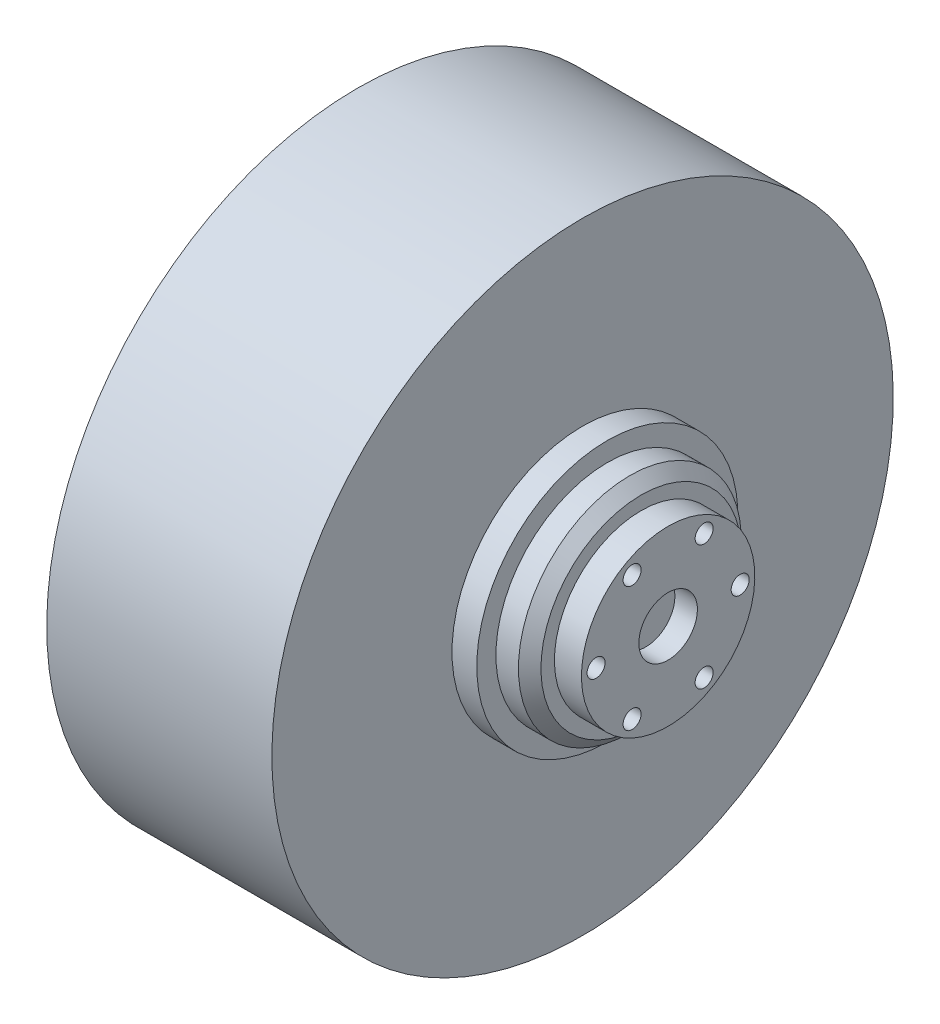
from build123d import *

# Parameters (mm, degrees)
SZKIC4_R                   = 4
WYTNIJ_WYCI_GNI_CIE1_DEPTH = 10
SZKIC5_R                   = 13
WYTNIJ_WYCI_GNI_CIE2_DEPTH = 10


with BuildPart() as part:
    # Szkic1 → Obrót1 (revolve)
    with BuildSketch(Plane.XY):
        Polygon((-90, -36.5), (-70, -36.5), (-70, -47), (-48, -47), (-48, -138), (52, -138), (52, -58), (63, -58), (63, -49.5), (73, -49.5), (78, -44.5), (78, -38.5), (90, -38.5), (90, 0), (-90, 0), align=None)
    revolve(axis=Axis((90, 0, 0), (-1, 0, 0)))

    # Szkic4 → Wytnij-wyciągnięcie1 (cut)
    with BuildSketch(Plane(origin=(90, 0, 0), x_dir=(0, 0, -1), z_dir=(1, 0, 0))):
        with Locations((16, 27.712812921)):
            Circle(SZKIC4_R)
        with Locations((32, 0)):
            Circle(SZKIC4_R)
        with Locations((16, -27.712812921)):
            Circle(SZKIC4_R)
        with Locations((-16, -27.712812921)):
            Circle(SZKIC4_R)
        with Locations((-32, 0)):
            Circle(SZKIC4_R)
        with Locations((-16, 27.712812921)):
            Circle(SZKIC4_R)
    extrude(amount=-WYTNIJ_WYCI_GNI_CIE1_DEPTH, mode=Mode.SUBTRACT)

    # Szkic5 → Wytnij-wyciągnięcie2 (cut)
    with BuildSketch(Plane(origin=(90, 0, 0), x_dir=(0, 0, -1), z_dir=(1, 0, 0))):
        Circle(SZKIC5_R)
    extrude(amount=-WYTNIJ_WYCI_GNI_CIE2_DEPTH, mode=Mode.SUBTRACT)


solid = part.part
